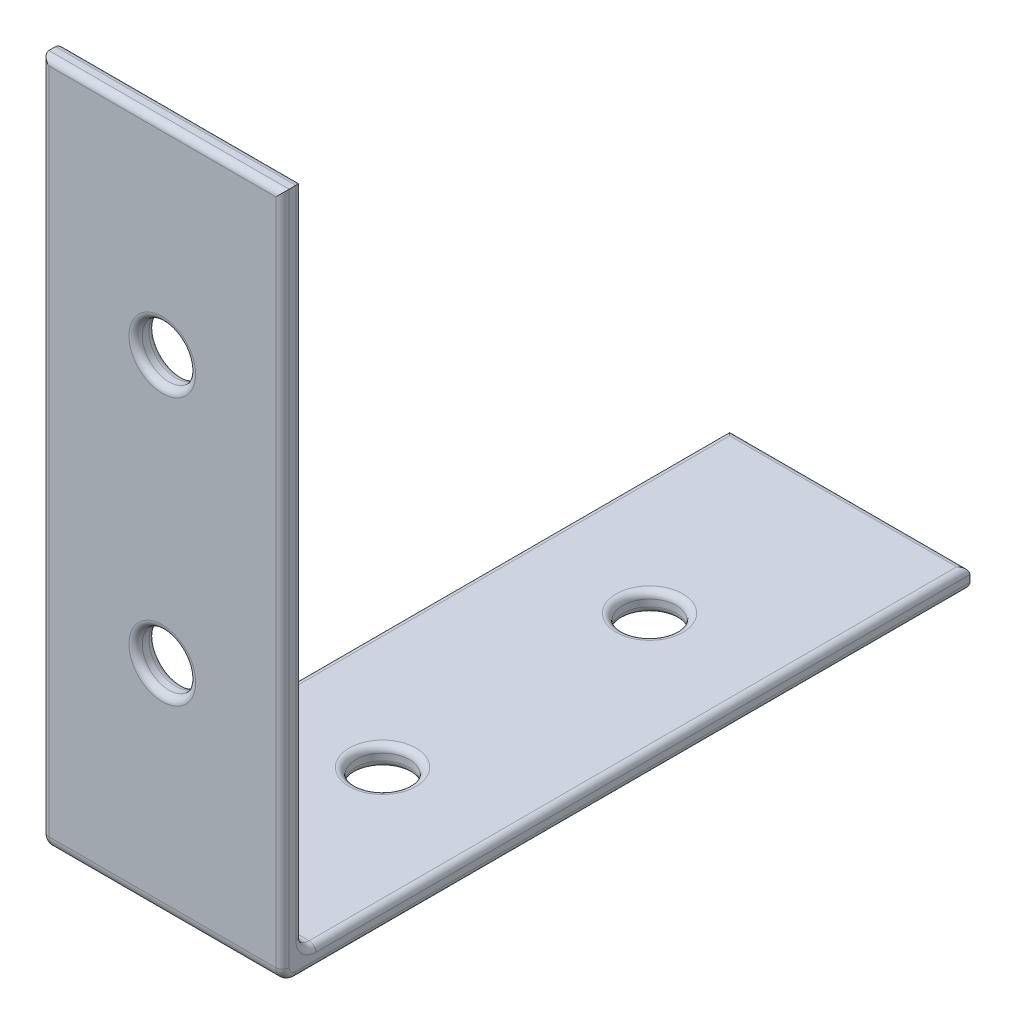
from build123d import *

# Parameters (mm, degrees)
BOSS_EXTRUDE1_DEPTH = 18
SKETCH2_R           = 2
CUT_EXTRUDE1_DEPTH  = 2.5
SKETCH3_R           = 2
CUT_EXTRUDE2_DEPTH  = 2.5
FILLET1_R           = 0.5


with BuildPart() as part:
    # Sketch1 → Boss-Extrude1 (new body)
    with BuildSketch(Plane(origin=(0, 0, 0), x_dir=(0, 0, -1), z_dir=(1, 0, 0))):
        with BuildLine():
            ThreePointArc((0, 1), (0.292893219, 0.292893219), (1, 0))
            Line((1, 0), (1.5, 0))
            Line((1.5, 0), (51.5, 0))
            Line((51.5, 0), (51.5, 1.5))
            Line((51.5, 1.5), (2.5, 1.5))
            ThreePointArc((2.5, 1.5), (1.792893219, 1.792893219), (1.5, 2.5))
            Line((1.5, 2.5), (1.5, 51.5))
            Line((1.5, 51.5), (0, 51.5))
            Line((0, 51.5), (0, 1.5))
            Line((0, 1.5), (0, 1))
        make_face()
    extrude(amount=BOSS_EXTRUDE1_DEPTH)

    # Sketch2 → Cut-Extrude1 (cut, through all)
    with BuildSketch(Plane(origin=(0, 1.5, 0), x_dir=(1, 0, 0), z_dir=(0, 1, 0))):
        with Locations((9, 16.5)):
            Circle(SKETCH2_R)
        with Locations((9, 36.5)):
            Circle(SKETCH2_R)
    extrude(amount=-CUT_EXTRUDE1_DEPTH, mode=Mode.SUBTRACT)

    # Sketch3 → Cut-Extrude2 (cut, through all)
    with BuildSketch(Plane(origin=(0, 0, -1.5), x_dir=(-1, 0, 0), z_dir=(0, 0, -1))):
        with Locations((-9, 16.5)):
            Circle(SKETCH3_R)
        with Locations((-9, 36.5)):
            Circle(SKETCH3_R)
    extrude(amount=-CUT_EXTRUDE2_DEPTH, mode=Mode.SUBTRACT)

    # Fillet1
    fillet1_edges = [part.edges().sort_by_distance(p)[0] for p in [
        (0, 27, -1.5),
        (0, 1.792893219, -1.792893219),
        (0, 1.5, -27),
        (0, 0, -26.25),
        (0, 0.292893219, -0.292893219),
        (9, 51.5, 0),
        (9, 51.5, -1.5),
        (9, 1.5, -51.5),
        (9, 0, -51.5),
        (18, 1.5, -27),
        (18, 1.792893219, -1.792893219),
        (18, 27, -1.5),
        (7, 0, -16.5),
        (7, 1.5, -16.5),
        (7, 0, -36.5),
        (7, 1.5, -36.5),
        (18, 26.25, 0),
        (11, 16.5, 0),
        (11, 16.5, -1.5),
        (11, 36.5, 0),
        (11, 36.5, -1.5),
        (18, 0.292893219, -0.292893219),
        (18, 0, -26.25),
        (0, 26.25, 0),
    ]]
    fillet(fillet1_edges, radius=FILLET1_R)


solid = part.part
